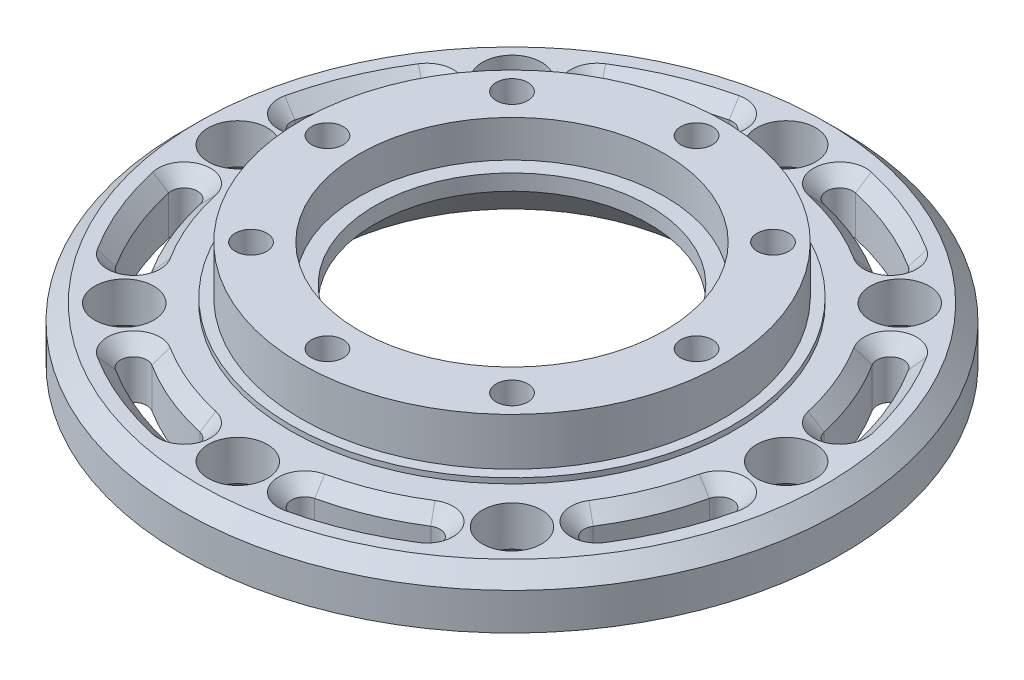
from build123d import *

# Parameters (mm, degrees)
SKETCH1_R            = 62.5
SKETCH1_R_2          = 5.5
SKETCH1_R_3          = 41.5
BOSS_EXTRUDE1_DEPTH  = 10
SKETCH2_R            = 41.5
SKETCH2_R_2          = 3.5
SKETCH2_R_3          = 30
BOSS_EXTRUDE2_DEPTH  = 10
BOSS_EXTRUDE3_START  = -10
SKETCH3_R            = 3.5
BOSS_EXTRUDE3_DEPTH  = 10
SKETCH4_R            = 41.5
SKETCH4_R_2          = 40
CUT_EXTRUDE1_DEPTH   = 10
CHAMFER1_SIZE        = 3
CUT_EXTRUDE4_DEPTH   = 13
SKETCH10_R           = 42
SKETCH10_R_2         = 40
BOSS_EXTRUDE4_DEPTH  = 1
BOSS_EXTRUDE9_DEPTH  = 10
CHAMFER7_SIZE        = 2.5
SKETCH18_R           = 3.5
BOSS_EXTRUDE10_DEPTH = 10
SKETCH19_R           = 3
CUT_EXTRUDE7_DEPTH   = 5
CUT_EXTRUDE8_DEPTH   = 15
CHAMFER9_SIZE        = 2.5
SKETCH21_R           = 5.6
CUT_EXTRUDE9_DEPTH   = 15
BOSS_EXTRUDE11_START = -5
SKETCH22_R           = 30
SKETCH22_R_2         = 26
BOSS_EXTRUDE11_DEPTH = 15
SKETCH23_R           = 30
SKETCH23_R_2         = 29
BOSS_EXTRUDE12_DEPTH = 5
CHAMFER10_SIZE       = 10
SKETCH24_R           = 29
SKETCH24_R_2         = 26
CUT_EXTRUDE10_DEPTH  = 2


with BuildPart() as part:
    # Sketch1 → Boss-Extrude1 (new body)
    with BuildSketch(Plane(origin=(0, 0, 0), x_dir=(1, 0, 0), z_dir=(0, 1, 0))):
        with Locations(Location((0, 0, 0), (0, 0, 270))):
            Circle(SKETCH1_R)
        with Locations(Location((-52, 0, 0), (0, 0, 270))):
            Circle(SKETCH1_R_2, mode=Mode.SUBTRACT)
        with Locations(Location((-36.769552622, 36.769552622, 0), (0, 0, 270))):
            Circle(SKETCH1_R_2, mode=Mode.SUBTRACT)
        with Locations(Location((0, 52, 0), (0, 0, 270))):
            Circle(SKETCH1_R_2, mode=Mode.SUBTRACT)
        with Locations(Location((36.769552622, 36.769552622, 0), (0, 0, 270))):
            Circle(SKETCH1_R_2, mode=Mode.SUBTRACT)
        with Locations(Location((52, 0, 0), (0, 0, 270))):
            Circle(SKETCH1_R_2, mode=Mode.SUBTRACT)
        with Locations(Location((36.769552622, -36.769552622, 0), (0, 0, 270))):
            Circle(SKETCH1_R_2, mode=Mode.SUBTRACT)
        with Locations(Location((0, -52, 0), (0, 0, 270))):
            Circle(SKETCH1_R_2, mode=Mode.SUBTRACT)
        with Locations(Location((-36.769552622, -36.769552622, 0), (0, 0, 270))):
            Circle(SKETCH1_R_2, mode=Mode.SUBTRACT)
        with Locations(Location((0, 0, 0), (0, 0, 270))):
            Circle(SKETCH1_R_3, mode=Mode.SUBTRACT)
    extrude(amount=BOSS_EXTRUDE1_DEPTH)

    # Sketch2 → Boss-Extrude2 (add, symmetric)
    with BuildSketch(Plane(origin=(0, 10, 0), x_dir=(1, 0, 0), z_dir=(0, 1, 0))):
        with Locations(Location((0, 0, 0), (0, 0, 270))):
            Circle(SKETCH2_R)
        with Locations(Location((0, -35, 0), (0, 0, 270))):
            Circle(SKETCH2_R_2, mode=Mode.SUBTRACT)
        with Locations(Location((-24.748737342, -24.748737342, 0), (0, 0, 270))):
            Circle(SKETCH2_R_2, mode=Mode.SUBTRACT)
        with Locations(Location((24.748737342, -24.748737342, 0), (0, 0, 270))):
            Circle(SKETCH2_R_2, mode=Mode.SUBTRACT)
        with Locations(Location((35, 0, 0), (0, 0, 270))):
            Circle(SKETCH2_R_2, mode=Mode.SUBTRACT)
        with BuildLine():
            ThreePointArc((-38.5, 0), (-35, 3.5), (-31.5, 0))
            ThreePointArc((-31.5, 0), (-35, -3.5), (-38.5, 0))
        make_face(mode=Mode.SUBTRACT)
        with Locations(Location((-24.748737342, 24.748737342, 0), (0, 0, 270))):
            Circle(SKETCH2_R_2, mode=Mode.SUBTRACT)
        with Locations(Location((0, 0, 0), (0, 0, 270))):
            Circle(SKETCH2_R_3, mode=Mode.SUBTRACT)
        with Locations(Location((24.748737342, 24.748737342, 0), (0, 0, 270))):
            Circle(SKETCH2_R_2, mode=Mode.SUBTRACT)
        with Locations(Location((0, 35, 0), (0, 0, 270))):
            Circle(SKETCH2_R_2, mode=Mode.SUBTRACT)
    extrude(amount=BOSS_EXTRUDE2_DEPTH, both=True)

    # Sketch3 → Boss-Extrude3 (add)
    with BuildSketch(Plane(origin=(0, 20, 0), x_dir=(1, 0, 0), z_dir=(0, 1, 0)).offset(BOSS_EXTRUDE3_START)):
        with Locations(Location((-35, 0, 0), (0, 0, 270))):
            Circle(SKETCH3_R)
        with Locations(Location((-24.748737342, 24.748737342, 0), (0, 0, 270))):
            Circle(SKETCH3_R)
        with Locations(Location((0, 35, 0), (0, 0, 270))):
            Circle(SKETCH3_R)
        with Locations(Location((24.748737342, 24.748737342, 0), (0, 0, 270))):
            Circle(SKETCH3_R)
        with Locations(Location((35, 0, 0), (0, 0, 270))):
            Circle(SKETCH3_R)
        with Locations(Location((24.748737342, -24.748737342, 0), (0, 0, 270))):
            Circle(SKETCH3_R)
        with Locations(Location((0, -35, 0), (0, 0, 270))):
            Circle(SKETCH3_R)
        with Locations(Location((-24.748737342, -24.748737342, 0), (0, 0, 270))):
            Circle(SKETCH3_R)
    extrude(amount=-BOSS_EXTRUDE3_DEPTH)

    # Sketch4 → Cut-Extrude1 (cut)
    with BuildSketch(Plane(origin=(0, 20, 0), x_dir=(1, 0, 0), z_dir=(0, 1, 0))):
        Circle(SKETCH4_R)
        with Locations(Location((0, 0, 0), (0, 0, 270))):
            Circle(SKETCH4_R_2, mode=Mode.SUBTRACT)
    extrude(amount=-CUT_EXTRUDE1_DEPTH, mode=Mode.SUBTRACT)

    # Chamfer1
    chamfer1_edges = [part.edges().sort_by_distance(p)[0] for p in [
        (0, 10, -62.5),
    ]]
    chamfer(chamfer1_edges, length=CHAMFER1_SIZE)

    # Sketch9 → Cut-Extrude4 (cut)
    with BuildSketch(Plane(origin=(0, 10, 0), x_dir=(1, 0, 0), z_dir=(0, 1, 0))):
        with BuildLine():
            ThreePointArc((-45.31509387, 30.2785777), (-50.351434522, 20.856247064), (-53.452797782, 10.63242255))
            ThreePointArc((-53.452797782, 10.63242255), (-51.488560386, 7.692733544), (-48.54887138, 9.65697094))
            ThreePointArc((-48.54887138, 9.65697094), (-45.732036859, 18.942829902), (-41.157745809, 27.500726534))
            ThreePointArc((-41.157745809, 27.500726534), (-41.847494257, 30.968326148), (-45.31509387, 30.2785777))
        make_face()
        with BuildLine():
            ThreePointArc((-10.63242255, 53.452797782), (-20.856247064, 50.351434522), (-30.2785777, 45.31509387))
            ThreePointArc((-30.2785777, 45.31509387), (-30.968326148, 41.847494257), (-27.500726534, 41.157745809))
            ThreePointArc((-27.500726534, 41.157745809), (-18.942829902, 45.732036859), (-9.65697094, 48.54887138))
            ThreePointArc((-9.65697094, 48.54887138), (-7.692733544, 51.488560386), (-10.63242255, 53.452797782))
        make_face()
        with BuildLine():
            ThreePointArc((30.2785777, 45.31509387), (20.856247064, 50.351434522), (10.63242255, 53.452797782))
            ThreePointArc((10.63242255, 53.452797782), (7.692733544, 51.488560386), (9.65697094, 48.54887138))
            ThreePointArc((9.65697094, 48.54887138), (18.942829902, 45.732036859), (27.500726534, 41.157745809))
            ThreePointArc((27.500726534, 41.157745809), (30.968326148, 41.847494257), (30.2785777, 45.31509387))
        make_face()
        with BuildLine():
            ThreePointArc((53.452797782, 10.63242255), (50.351434522, 20.856247064), (45.31509387, 30.2785777))
            ThreePointArc((45.31509387, 30.2785777), (41.847494257, 30.968326148), (41.157745809, 27.500726534))
            ThreePointArc((41.157745809, 27.500726534), (45.732036859, 18.942829902), (48.54887138, 9.65697094))
            ThreePointArc((48.54887138, 9.65697094), (51.488560386, 7.692733544), (53.452797782, 10.63242255))
        make_face()
        with BuildLine():
            ThreePointArc((45.31509387, -30.2785777), (50.351434522, -20.856247064), (53.452797782, -10.63242255))
            ThreePointArc((53.452797782, -10.63242255), (51.488560386, -7.692733544), (48.54887138, -9.65697094))
            ThreePointArc((48.54887138, -9.65697094), (45.732036859, -18.942829902), (41.157745809, -27.500726534))
            ThreePointArc((41.157745809, -27.500726534), (41.847494257, -30.968326148), (45.31509387, -30.2785777))
        make_face()
        with BuildLine():
            ThreePointArc((10.63242255, -53.452797782), (20.856247064, -50.351434522), (30.2785777, -45.31509387))
            ThreePointArc((30.2785777, -45.31509387), (30.968326148, -41.847494257), (27.500726534, -41.157745809))
            ThreePointArc((27.500726534, -41.157745809), (18.942829902, -45.732036859), (9.65697094, -48.54887138))
            ThreePointArc((9.65697094, -48.54887138), (7.692733544, -51.488560386), (10.63242255, -53.452797782))
        make_face()
        with BuildLine():
            ThreePointArc((-30.2785777, -45.31509387), (-20.856247064, -50.351434522), (-10.63242255, -53.452797782))
            ThreePointArc((-10.63242255, -53.452797782), (-7.692733544, -51.488560386), (-9.65697094, -48.54887138))
            ThreePointArc((-9.65697094, -48.54887138), (-18.942829902, -45.732036859), (-27.500726534, -41.157745809))
            ThreePointArc((-27.500726534, -41.157745809), (-30.968326148, -41.847494257), (-30.2785777, -45.31509387))
        make_face()
        with BuildLine():
            ThreePointArc((-53.452797782, -10.63242255), (-50.351434522, -20.856247064), (-45.31509387, -30.2785777))
            ThreePointArc((-45.31509387, -30.2785777), (-41.847494257, -30.968326148), (-41.157745809, -27.500726534))
            ThreePointArc((-41.157745809, -27.500726534), (-45.732036859, -18.942829902), (-48.54887138, -9.65697094))
            ThreePointArc((-48.54887138, -9.65697094), (-51.488560386, -7.692733544), (-53.452797782, -10.63242255))
        make_face()
    extrude(amount=-CUT_EXTRUDE4_DEPTH, mode=Mode.SUBTRACT)

    # Sketch10 → Boss-Extrude4 (add)
    with BuildSketch(Plane(origin=(0, 10, 0), x_dir=(1, 0, 0), z_dir=(0, 1, 0))):
        with Locations(Location((0, 0, 0), (0, 0, 270))):
            Circle(SKETCH10_R)
        with Locations(Location((0, 0, 0), (0, 0, 270))):
            Circle(SKETCH10_R_2, mode=Mode.SUBTRACT)
    extrude(amount=BOSS_EXTRUDE4_DEPTH)

    # Sketch17 → Boss-Extrude9 (add)
    with BuildSketch(Plane(origin=(0, 10, 0), x_dir=(1, 0, 0), z_dir=(0, 1, 0))):
        with BuildLine():
            ThreePointArc((-45.31509387, 30.2785777), (-50.351434522, 20.856247064), (-53.452797782, 10.63242255))
            ThreePointArc((-53.452797782, 10.63242255), (-51.488560386, 7.692733544), (-48.54887138, 9.65697094))
            ThreePointArc((-48.54887138, 9.65697094), (-45.732036859, 18.942829902), (-41.157745809, 27.500726534))
            ThreePointArc((-41.157745809, 27.500726534), (-41.847494257, 30.968326148), (-45.31509387, 30.2785777))
        make_face()
        with BuildLine():
            ThreePointArc((-10.63242255, 53.452797782), (-20.856247064, 50.351434522), (-30.2785777, 45.31509387))
            ThreePointArc((-30.2785777, 45.31509387), (-30.968326148, 41.847494257), (-27.500726534, 41.157745809))
            ThreePointArc((-27.500726534, 41.157745809), (-18.942829902, 45.732036859), (-9.65697094, 48.54887138))
            ThreePointArc((-9.65697094, 48.54887138), (-7.692733544, 51.488560386), (-10.63242255, 53.452797782))
        make_face()
        with BuildLine():
            ThreePointArc((30.2785777, 45.31509387), (20.856247064, 50.351434522), (10.63242255, 53.452797782))
            ThreePointArc((10.63242255, 53.452797782), (7.692733544, 51.488560386), (9.65697094, 48.54887138))
            ThreePointArc((9.65697094, 48.54887138), (18.942829902, 45.732036859), (27.500726534, 41.157745809))
            ThreePointArc((27.500726534, 41.157745809), (30.968326148, 41.847494257), (30.2785777, 45.31509387))
        make_face()
        with BuildLine():
            ThreePointArc((53.452797782, 10.63242255), (50.351434522, 20.856247064), (45.31509387, 30.2785777))
            ThreePointArc((45.31509387, 30.2785777), (41.847494257, 30.968326148), (41.157745809, 27.500726534))
            ThreePointArc((41.157745809, 27.500726534), (45.732036859, 18.942829902), (48.54887138, 9.65697094))
            ThreePointArc((48.54887138, 9.65697094), (51.488560386, 7.692733544), (53.452797782, 10.63242255))
        make_face()
        with BuildLine():
            ThreePointArc((45.31509387, -30.2785777), (50.351434522, -20.856247064), (53.452797782, -10.63242255))
            ThreePointArc((53.452797782, -10.63242255), (51.488560386, -7.692733544), (48.54887138, -9.65697094))
            ThreePointArc((48.54887138, -9.65697094), (45.732036859, -18.942829902), (41.157745809, -27.500726534))
            ThreePointArc((41.157745809, -27.500726534), (41.847494257, -30.968326148), (45.31509387, -30.2785777))
        make_face()
        with BuildLine():
            ThreePointArc((10.63242255, -53.452797782), (20.856247064, -50.351434522), (30.2785777, -45.31509387))
            ThreePointArc((30.2785777, -45.31509387), (30.968326148, -41.847494257), (27.500726534, -41.157745809))
            ThreePointArc((27.500726534, -41.157745809), (18.942829902, -45.732036859), (9.65697094, -48.54887138))
            ThreePointArc((9.65697094, -48.54887138), (7.692733544, -51.488560386), (10.63242255, -53.452797782))
        make_face()
        with BuildLine():
            ThreePointArc((-30.2785777, -45.31509387), (-20.856247064, -50.351434522), (-10.63242255, -53.452797782))
            ThreePointArc((-10.63242255, -53.452797782), (-7.692733544, -51.488560386), (-9.65697094, -48.54887138))
            ThreePointArc((-9.65697094, -48.54887138), (-18.942829902, -45.732036859), (-27.500726534, -41.157745809))
            ThreePointArc((-27.500726534, -41.157745809), (-30.968326148, -41.847494257), (-30.2785777, -45.31509387))
        make_face()
        with BuildLine():
            ThreePointArc((-53.452797782, -10.63242255), (-50.351434522, -20.856247064), (-45.31509387, -30.2785777))
            ThreePointArc((-45.31509387, -30.2785777), (-41.847494257, -30.968326148), (-41.157745809, -27.500726534))
            ThreePointArc((-41.157745809, -27.500726534), (-45.732036859, -18.942829902), (-48.54887138, -9.65697094))
            ThreePointArc((-48.54887138, -9.65697094), (-51.488560386, -7.692733544), (-53.452797782, -10.63242255))
        make_face()
    extrude(amount=-BOSS_EXTRUDE9_DEPTH)

    # Chamfer7
    chamfer7_edges = [part.edges().sort_by_distance(p)[0] for p in [
        (-36.769552622, 0, 31.269552622),
        (-52, 0, -5.5),
        (-36.769552622, 0, -42.269552622),
        (0, 0, -57.5),
        (36.769552622, 0, -42.269552622),
        (52, 0, -5.5),
        (36.769552622, 0, 31.269552622),
        (0, 0, 46.5),
    ]]
    chamfer(chamfer7_edges, length=CHAMFER7_SIZE)

    # Sketch18 → Boss-Extrude10 (add)
    with BuildSketch(Plane(origin=(0, 10, 0), x_dir=(1, 0, 0), z_dir=(0, 1, 0))):
        with Locations((0, 35)):
            Circle(SKETCH18_R)
        with Locations((24.748737342, 24.748737342)):
            Circle(SKETCH18_R)
        with Locations((35, 0)):
            Circle(SKETCH18_R)
        with Locations((24.748737342, -24.748737342)):
            Circle(SKETCH18_R)
        with Locations((0, -35)):
            Circle(SKETCH18_R)
        with Locations((-24.748737342, -24.748737342)):
            Circle(SKETCH18_R)
        with Locations((-35, 0)):
            Circle(SKETCH18_R)
        with Locations((-24.748737342, 24.748737342)):
            Circle(SKETCH18_R)
    extrude(amount=BOSS_EXTRUDE10_DEPTH)

    # Sketch19 → Cut-Extrude7 (cut)
    with BuildSketch(Plane(origin=(0, 20, 0), x_dir=(1, 0, 0), z_dir=(0, 1, 0))):
        with Locations(Location((-24.748737342, 24.748737342, 0), (0, 0, 270))):
            Circle(SKETCH19_R)
        with Locations(Location((0, 35, 0), (0, 0, 270))):
            Circle(SKETCH19_R)
        with Locations(Location((35, 0, 0), (0, 0, 270))):
            Circle(SKETCH19_R)
        with Locations(Location((24.748737342, -24.748737342, 0), (0, 0, 270))):
            Circle(SKETCH19_R)
        with Locations(Location((0, -35, 0), (0, 0, 270))):
            Circle(SKETCH19_R)
        with Locations(Location((-24.748737342, -24.748737342, 0), (0, 0, 270))):
            Circle(SKETCH19_R)
        with BuildLine():
            ThreePointArc((-38, 0), (-35, -3), (-32, 0))
            Line((-32, 0), (-38, 0))
        make_face()
        with BuildLine():
            Line((-38, 0), (-32, 0))
            ThreePointArc((-32, 0), (-35, 3), (-38, 0))
        make_face()
        with Locations(Location((24.748737342, 24.748737342, 0), (0, 0, 270))):
            Circle(SKETCH19_R)
    extrude(amount=-CUT_EXTRUDE7_DEPTH, mode=Mode.SUBTRACT)

    # Sketch20 → Cut-Extrude8 (cut)
    with BuildSketch(Plane(origin=(0, 10, 0), x_dir=(1, 0, 0), z_dir=(0, 1, 0))):
        with BuildLine():
            ThreePointArc((-46.065319954, 29.124496521), (-50.351434522, 20.856247064), (-53.167229105, 11.978971128))
            ThreePointArc((-53.167229105, 11.978971128), (-51.277859473, 8.990613319), (-48.289501664, 10.879982951))
            ThreePointArc((-48.289501664, 10.879982951), (-45.732036859, 18.942829902), (-41.839143811, 26.452524363))
            ThreePointArc((-41.839143811, 26.452524363), (-42.616245803, 29.901598513), (-46.065319954, 29.124496521))
        make_face()
        with BuildLine():
            ThreePointArc((-11.978971128, 53.167229105), (-20.856247064, 50.351434522), (-29.124496521, 46.065319954))
            ThreePointArc((-29.124496521, 46.065319954), (-29.901598513, 42.616245803), (-26.452524363, 41.839143811))
            ThreePointArc((-26.452524363, 41.839143811), (-18.942829902, 45.732036859), (-10.879982951, 48.289501664))
            ThreePointArc((-10.879982951, 48.289501664), (-8.990613319, 51.277859473), (-11.978971128, 53.167229105))
        make_face()
        with BuildLine():
            ThreePointArc((29.124496521, 46.065319954), (20.856247064, 50.351434522), (11.978971128, 53.167229105))
            ThreePointArc((11.978971128, 53.167229105), (8.990613319, 51.277859473), (10.879982951, 48.289501664))
            ThreePointArc((10.879982951, 48.289501664), (18.942829902, 45.732036859), (26.452524363, 41.839143811))
            ThreePointArc((26.452524363, 41.839143811), (29.901598513, 42.616245803), (29.124496521, 46.065319954))
        make_face()
        with BuildLine():
            ThreePointArc((53.167229105, 11.978971128), (50.351434522, 20.856247064), (46.065319954, 29.124496521))
            ThreePointArc((46.065319954, 29.124496521), (42.616245803, 29.901598513), (41.839143811, 26.452524363))
            ThreePointArc((41.839143811, 26.452524363), (45.732036859, 18.942829902), (48.289501664, 10.879982951))
            ThreePointArc((48.289501664, 10.879982951), (51.277859473, 8.990613319), (53.167229105, 11.978971128))
        make_face()
        with BuildLine():
            ThreePointArc((46.065319954, -29.124496521), (50.351434522, -20.856247064), (53.167229105, -11.978971128))
            ThreePointArc((53.167229105, -11.978971128), (51.277859473, -8.990613319), (48.289501664, -10.879982951))
            ThreePointArc((48.289501664, -10.879982951), (45.732036859, -18.942829902), (41.839143811, -26.452524363))
            ThreePointArc((41.839143811, -26.452524363), (42.616245803, -29.901598513), (46.065319954, -29.124496521))
        make_face()
        with BuildLine():
            ThreePointArc((11.978971128, -53.167229105), (20.856247064, -50.351434522), (29.124496521, -46.065319954))
            ThreePointArc((29.124496521, -46.065319954), (29.901598513, -42.616245803), (26.452524363, -41.839143811))
            ThreePointArc((26.452524363, -41.839143811), (18.942829902, -45.732036859), (10.879982951, -48.289501664))
            ThreePointArc((10.879982951, -48.289501664), (8.990613319, -51.277859473), (11.978971128, -53.167229105))
        make_face()
        with BuildLine():
            ThreePointArc((-29.124496521, -46.065319954), (-20.856247064, -50.351434522), (-11.978971128, -53.167229105))
            ThreePointArc((-11.978971128, -53.167229105), (-8.990613319, -51.277859473), (-10.879982951, -48.289501664))
            ThreePointArc((-10.879982951, -48.289501664), (-18.942829902, -45.732036859), (-26.452524363, -41.839143811))
            ThreePointArc((-26.452524363, -41.839143811), (-29.901598513, -42.616245803), (-29.124496521, -46.065319954))
        make_face()
        with BuildLine():
            ThreePointArc((-53.167229105, -11.978971128), (-50.351434522, -20.856247064), (-46.065319954, -29.124496521))
            ThreePointArc((-46.065319954, -29.124496521), (-42.616245803, -29.901598513), (-41.839143811, -26.452524363))
            ThreePointArc((-41.839143811, -26.452524363), (-45.732036859, -18.942829902), (-48.289501664, -10.879982951))
            ThreePointArc((-48.289501664, -10.879982951), (-51.277859473, -8.990613319), (-53.167229105, -11.978971128))
        make_face()
    extrude(amount=-CUT_EXTRUDE8_DEPTH, mode=Mode.SUBTRACT)

    # Chamfer9
    chamfer9_edges = [part.edges().sort_by_distance(p)[0] for p in [
        (-8.990613319, 10, -51.277859473),
        (-20.856247064, 10, -50.351434522),
        (-29.901598513, 10, -42.616245803),
        (-18.942829902, 10, -45.732036859),
        (29.901598513, 10, -42.616245803),
        (20.856247064, 10, -50.351434522),
        (8.990613319, 10, -51.277859473),
        (18.942829902, 10, -45.732036859),
        (51.277859473, 10, -8.990613319),
        (50.351434522, 10, -20.856247064),
        (42.616245803, 10, -29.901598513),
        (45.732036859, 10, -18.942829902),
        (42.616245803, 10, 29.901598513),
        (50.351434522, 10, 20.856247064),
        (51.277859473, 10, 8.990613319),
        (45.732036859, 10, 18.942829902),
        (8.990613319, 10, 51.277859473),
        (20.856247064, 10, 50.351434522),
        (29.901598513, 10, 42.616245803),
        (18.942829902, 10, 45.732036859),
        (-29.901598513, 10, 42.616245803),
        (-20.856247064, 10, 50.351434522),
        (-8.990613319, 10, 51.277859473),
        (-18.942829902, 10, 45.732036859),
        (-51.277859473, 10, 8.990613319),
        (-50.351434522, 10, 20.856247064),
        (-42.616245803, 10, 29.901598513),
        (-45.732036859, 10, 18.942829902),
        (-42.616245803, 10, -29.901598513),
        (-50.351434522, 10, -20.856247064),
        (-51.277859473, 10, -8.990613319),
        (-45.732036859, 10, -18.942829902),
    ]]
    chamfer(chamfer9_edges, length=CHAMFER9_SIZE)

    # Sketch21 → Cut-Extrude9 (cut)
    with BuildSketch(Plane(origin=(0, 10, 0), x_dir=(1, 0, 0), z_dir=(0, 1, 0))):
        with Locations(Location((-52, 0, 0), (0, 0, 270))):
            Circle(SKETCH21_R)
        with Locations(Location((-36.769552622, 36.769552622, 0), (0, 0, 270))):
            Circle(SKETCH21_R)
        with Locations(Location((0, 52, 0), (0, 0, 270))):
            Circle(SKETCH21_R)
        with Locations(Location((36.769552622, 36.769552622, 0), (0, 0, 270))):
            Circle(SKETCH21_R)
        with Locations(Location((52, 0, 0), (0, 0, 270))):
            Circle(SKETCH21_R)
        with Locations(Location((36.769552622, -36.769552622, 0), (0, 0, 270))):
            Circle(SKETCH21_R)
        with Locations(Location((0, -52, 0), (0, 0, 270))):
            Circle(SKETCH21_R)
        with Locations(Location((-36.769552622, -36.769552622, 0), (0, 0, 270))):
            Circle(SKETCH21_R)
    extrude(amount=-CUT_EXTRUDE9_DEPTH, mode=Mode.SUBTRACT)

    # Sketch22 → Boss-Extrude11 (add)
    with BuildSketch(Plane(origin=(0, 20, 0), x_dir=(1, 0, 0), z_dir=(0, 1, 0)).offset(BOSS_EXTRUDE11_START)):
        with Locations(Location((0, 0, 0), (0, 0, 270))):
            Circle(SKETCH22_R)
        with Locations(Location((0, 0, 0), (0, 0, 270))):
            Circle(SKETCH22_R_2, mode=Mode.SUBTRACT)
    extrude(amount=-BOSS_EXTRUDE11_DEPTH)

    # Sketch23 → Boss-Extrude12 (add)
    with BuildSketch(Plane(origin=(0, 15, 0), x_dir=(1, 0, 0), z_dir=(0, 1, 0))):
        Circle(SKETCH23_R)
        with Locations(Location((0, 0, 0), (0, 0, 270))):
            Circle(SKETCH23_R_2, mode=Mode.SUBTRACT)
    extrude(amount=BOSS_EXTRUDE12_DEPTH)

    # Chamfer10
    chamfer10_edges = [part.edges().sort_by_distance(p)[0] for p in [
        (0, 0, -26),
    ]]
    chamfer(chamfer10_edges, length=CHAMFER10_SIZE)

    # Sketch24 → Cut-Extrude10 (cut)
    with BuildSketch(Plane(origin=(0, 15, 0), x_dir=(1, 0, 0), z_dir=(0, 1, 0))):
        with Locations(Location((0, 0, 0), (0, 0, 270))):
            Circle(SKETCH24_R)
        with Locations(Location((0, 0, 0), (0, 0, 270))):
            Circle(SKETCH24_R_2, mode=Mode.SUBTRACT)
    extrude(amount=-CUT_EXTRUDE10_DEPTH, mode=Mode.SUBTRACT)


solid = part.part
